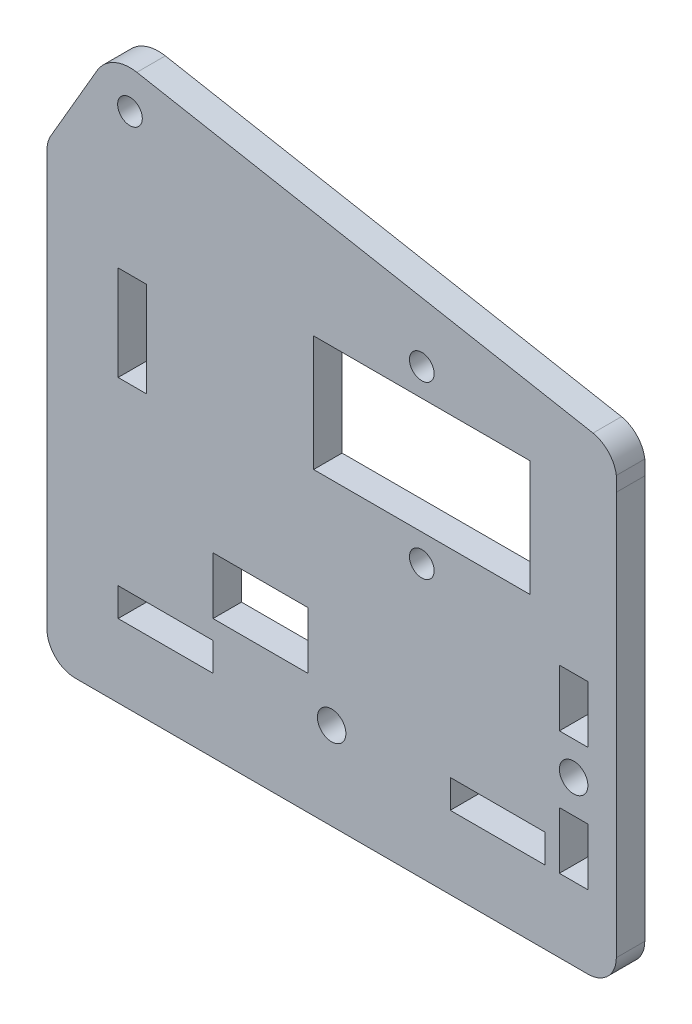
from build123d import *

# Parameters (mm, degrees)
MODEL_R             = 1.3
MODEL_R_2           = 1.500000002
MODEL_W             = 3
MODEL_H             = 10
MODEL_W_2           = 10
MODEL_H_2           = 3
MODEL_H_3           = 6
MODEL_W_3           = 22.8
MODEL_H_4           = 12.2
BOSS_EXTRUDE1_DEPTH = 3


with BuildPart() as part:
    # Model → Boss-Extrude1 (new body)
    with BuildSketch(Plane.XY):
        with BuildLine():
            Line((21.96271471, 39.580829954), (21.96276757, 58.495922142))
            ThreePointArc((21.96276757, 58.495922142), (22.066046655, 59.276171923), (22.368675297, 60.00272006))
            Line((22.368675297, 60.00272006), (25.427717727, 65.269480806))
            Line((25.427717727, 65.269480806), (27.25161841, 68.40969502))
            ThreePointArc((27.25161841, 68.40969502), (29.03985645, 70.035063012), (31.437828278, 70.333973552))
            Line((31.437828278, 70.333973552), (79.508282697, 61.445627037))
            ThreePointArc((79.508282697, 61.445627037), (81.151311996, 60.514547069), (81.963503617, 58.809613066))
            Line((81.963503617, 58.809613066), (81.989341148, 57.295464993))
            Line((81.989341148, 57.295464993), (81.962758854, 14.795654622))
            ThreePointArc((81.962758854, 14.795654622), (81.08382665, 12.674474539), (78.962495601, 11.795906758))
            Line((78.962495601, 11.795906758), (24.962535775, 11.795906758))
            ThreePointArc((24.962535775, 11.795906758), (22.841288266, 12.674619651), (21.962651159, 14.795898552))
            Line((21.962651159, 14.795898552), (21.96271471, 39.580829954))
        make_face()
        with Locations((61.462672705, 58.495778552)):
            Circle(MODEL_R, mode=Mode.SUBTRACT)
        with Locations((61.462672705, 40.495778552)):
            Circle(MODEL_R, mode=Mode.SUBTRACT)
        with Locations((30.710508107, 66.400677282)):
            Circle(MODEL_R, mode=Mode.SUBTRACT)
        with Locations((51.962675263, 20.995768297)):
            Circle(MODEL_R_2, mode=Mode.SUBTRACT)
        with Locations((77.462616288, 28.995637525)):
            Circle(MODEL_R_2, mode=Mode.SUBTRACT)
        with Locations((30.962567569, 46.495883681)):
            Rectangle(MODEL_W, MODEL_H, mode=Mode.SUBTRACT)
        with Locations((34.462567569, 20.995883681)):
            Rectangle(MODEL_W_2, MODEL_H_2, mode=Mode.SUBTRACT)
        with Locations((69.462567569, 20.995883681)):
            Rectangle(MODEL_W_2, MODEL_H_2, mode=Mode.SUBTRACT)
        with Locations((77.462598338, 22.495645219)):
            Rectangle(MODEL_W, MODEL_H_3, mode=Mode.SUBTRACT)
        with Locations((61.462721415, 49.495778552)):
            Rectangle(MODEL_W_3, MODEL_H_4, mode=Mode.SUBTRACT)
        with Locations((77.462598338, 35.495645219)):
            Rectangle(MODEL_W, MODEL_H_3, mode=Mode.SUBTRACT)
        with Locations((44.462670134, 27.495883681)):
            Rectangle(MODEL_W_2, MODEL_H_3, mode=Mode.SUBTRACT)
    extrude(amount=BOSS_EXTRUDE1_DEPTH)


solid = part.part
